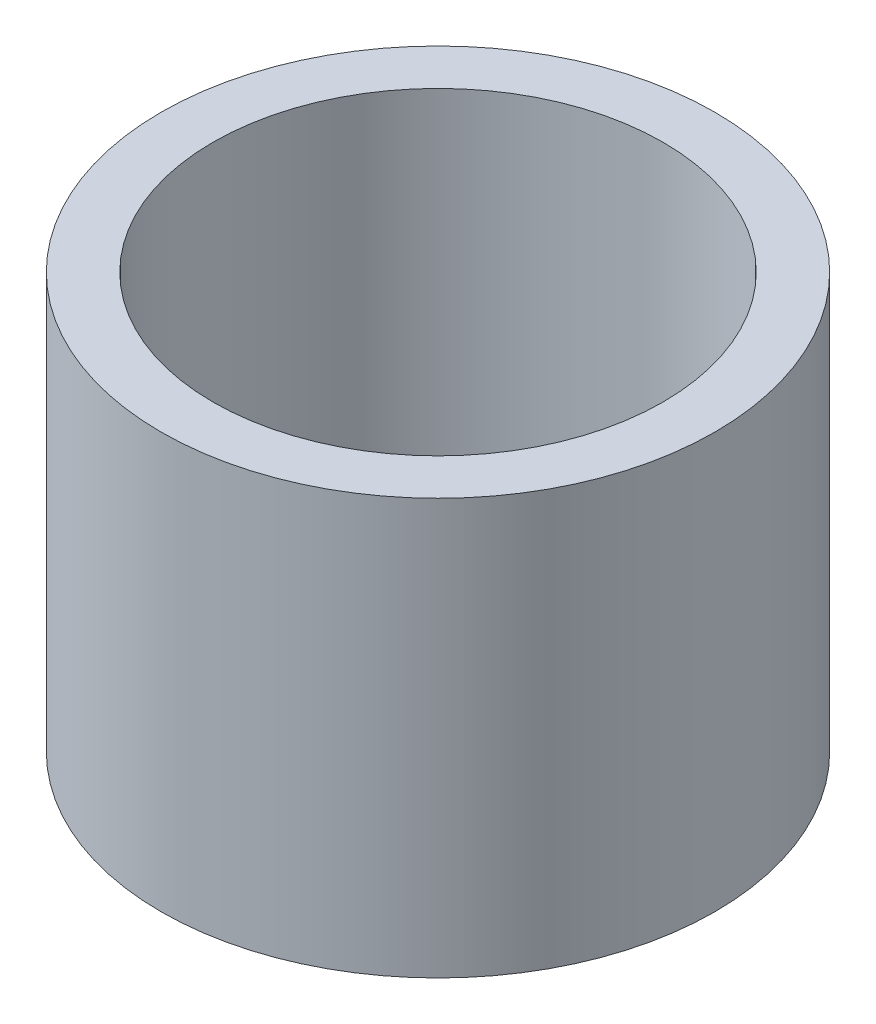
from build123d import *

# Parameters (mm, degrees)
SKETCH1_W = 9.525
SKETCH1_H = 76.2


with BuildPart() as part:
    # Sketch1 → Revolve1 (revolve)
    with BuildSketch(Plane.XY):
        with Locations((46.0375, 38.1)):
            Rectangle(SKETCH1_W, SKETCH1_H)
    revolve(axis=Axis((0, -1000, 0), (0, 1, 0)))


solid = part.part
